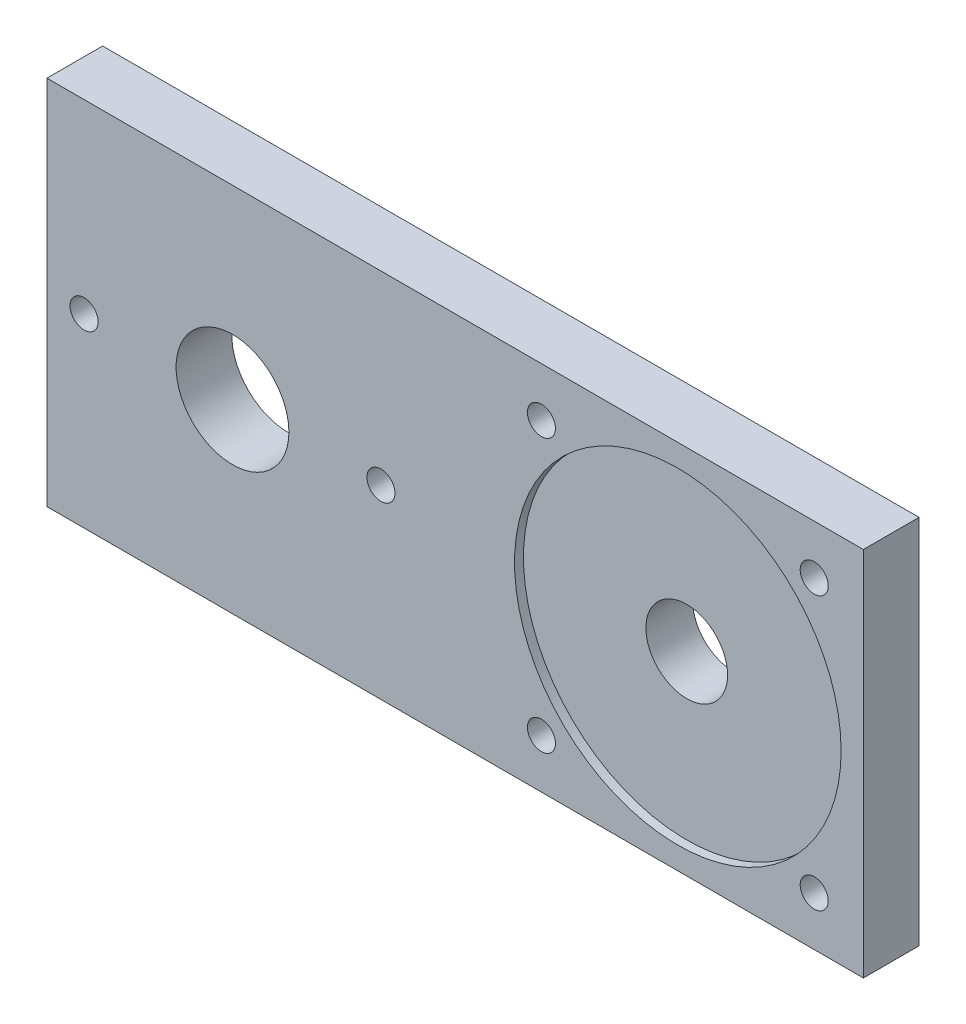
from build123d import *

# Parameters (mm, degrees)
SKETCH1_W           = 152.4
SKETCH1_H           = 76.2
BOSS_EXTRUDE1_DEPTH = 9.525
SKETCH2_R           = 9.652
SKETCH2_R_2         = 6.985
SKETCH2_R_3         = 2.4003
CUT_EXTRUDE1_DEPTH  = 9.525
SKETCH3_R           = 27.94
CUT_EXTRUDE2_DEPTH  = 1.524
SKETCH4_W           = 152.4
SKETCH4_H           = 76.2
SKETCH4_W_2         = 139.7
SKETCH4_H_2         = 63.5
CUT_EXTRUDE3_DEPTH  = 10.525


with BuildPart() as part:
    # Sketch1 → Boss-Extrude1 (new body)
    with BuildSketch(Plane.XY):
        with Locations((76.2, 38.1)):
            Rectangle(SKETCH1_W, SKETCH1_H)
    extrude(amount=BOSS_EXTRUDE1_DEPTH)

    # Sketch2 → Cut-Extrude1 (cut)
    with BuildSketch(Plane.XY.offset(9.525)):
        with Locations((38.1, 38.1)):
            Circle(SKETCH2_R)
        with Locations((114.3, 38.1)):
            Circle(SKETCH2_R_2)
        with Locations((12.7, 38.1)):
            Circle(SKETCH2_R_3)
        with Locations((63.5, 38.1)):
            Circle(SKETCH2_R_3)
        with Locations((90.95994, 61.44006)):
            Circle(SKETCH2_R_3)
        with Locations((137.64006, 61.44006)):
            Circle(SKETCH2_R_3)
        with Locations((90.95994, 14.75994)):
            Circle(SKETCH2_R_3)
        with Locations((137.64006, 14.75994)):
            Circle(SKETCH2_R_3)
    extrude(amount=-CUT_EXTRUDE1_DEPTH, mode=Mode.SUBTRACT)

    # Sketch3 → Cut-Extrude2 (cut)
    with BuildSketch(Plane.XY.offset(9.525)):
        with Locations((114.3, 38.1)):
            Circle(SKETCH3_R)
    extrude(amount=-CUT_EXTRUDE2_DEPTH, mode=Mode.SUBTRACT)

    # Sketch4 → Cut-Extrude3 (cut, through all)
    with BuildSketch(Plane(origin=(0, 0, 0), x_dir=(-1, 0, 0), z_dir=(0, 0, -1))):
        with Locations((-76.2, 38.1)):
            Rectangle(SKETCH4_W, SKETCH4_H)
        with Locations((-76.2, 38.1)):
            Rectangle(SKETCH4_W_2, SKETCH4_H_2, mode=Mode.SUBTRACT)
    extrude(amount=-CUT_EXTRUDE3_DEPTH, mode=Mode.SUBTRACT)


solid = part.part
